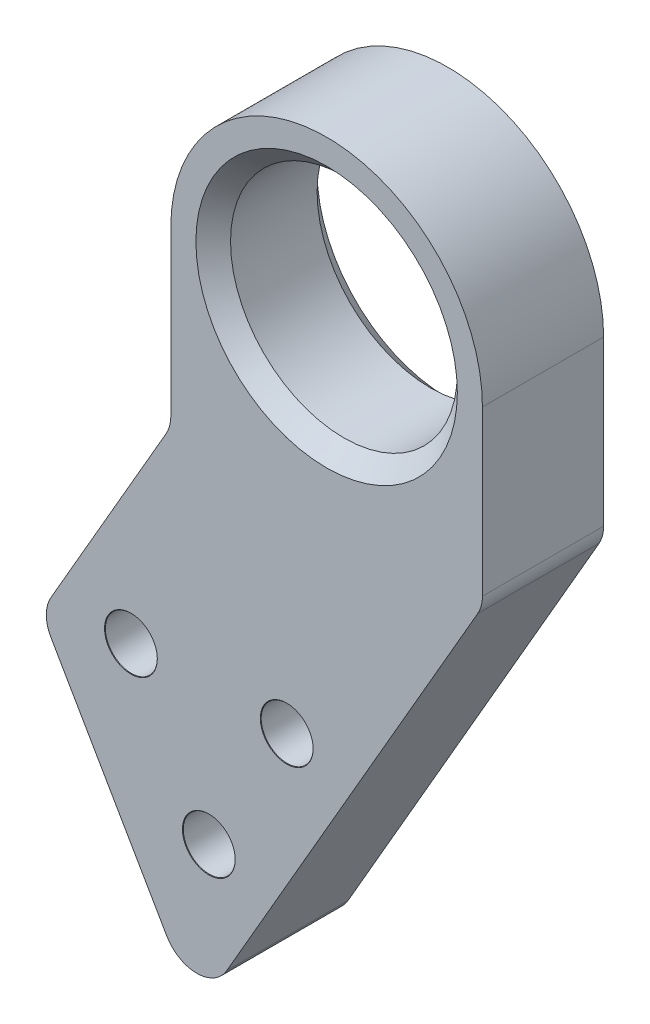
from build123d import *

# Parameters (mm, degrees)
SKETCH1_R                       = 6.55
BOSS_EXTRUDE1_DEPTH             = 7
CHAMFER1_SIZE                   = 1
FILLET1_R                       = 2
F_3_0MM_DOWEL_HOLE1_D           = 3
F_3_0MM_DOWEL_HOLE1_CSINK_D     = 3.05
F_3_0MM_DOWEL_HOLE1_CSINK_ANGLE = 90


with BuildPart() as part:
    # Sketch1 → Boss-Extrude1 (new body)
    with BuildSketch(Plane.XY):
        with BuildLine():
            Line((-9, 0), (-9, -10))
            Line((-9, -10), (-16.5, -22.990381057))
            Line((-16.5, -22.990381057), (-7.5, -38.578838325))
            Line((-7.5, -38.578838325), (9, -10))
            Line((9, -10), (9, 0))
            ThreePointArc((9, 0), (0, 9), (-9, 0))
        make_face()
        Circle(SKETCH1_R, mode=Mode.SUBTRACT)
    extrude(amount=BOSS_EXTRUDE1_DEPTH)

    # Chamfer1
    chamfer1_edges = [part.edges().sort_by_distance(p)[0] for p in [
        (-6.55, 0, 0),
        (-6.55, 0, 7),
    ]]
    chamfer(chamfer1_edges, length=CHAMFER1_SIZE)

    # Fillet1
    fillet1_edges = [part.edges().sort_by_distance(p)[0] for p in [
        (9, -10, 3.5),
        (-7.5, -38.578838325, 3.5),
        (-16.5, -22.990381057, 3.5),
        (-9, -10, 3.5),
    ]]
    fillet(fillet1_edges, radius=FILLET1_R)

    # Ø3.0mm Dowel Hole1 (through all)
    with Locations(Plane.XY.offset(7)):
        with Locations((-11.303847577, -21.990381057), (-6.803847577, -29.784609691), (-2.303847577, -21.990381057)):
            CounterSinkHole(F_3_0MM_DOWEL_HOLE1_D / 2, F_3_0MM_DOWEL_HOLE1_CSINK_D / 2, counter_sink_angle=F_3_0MM_DOWEL_HOLE1_CSINK_ANGLE)


solid = part.part
